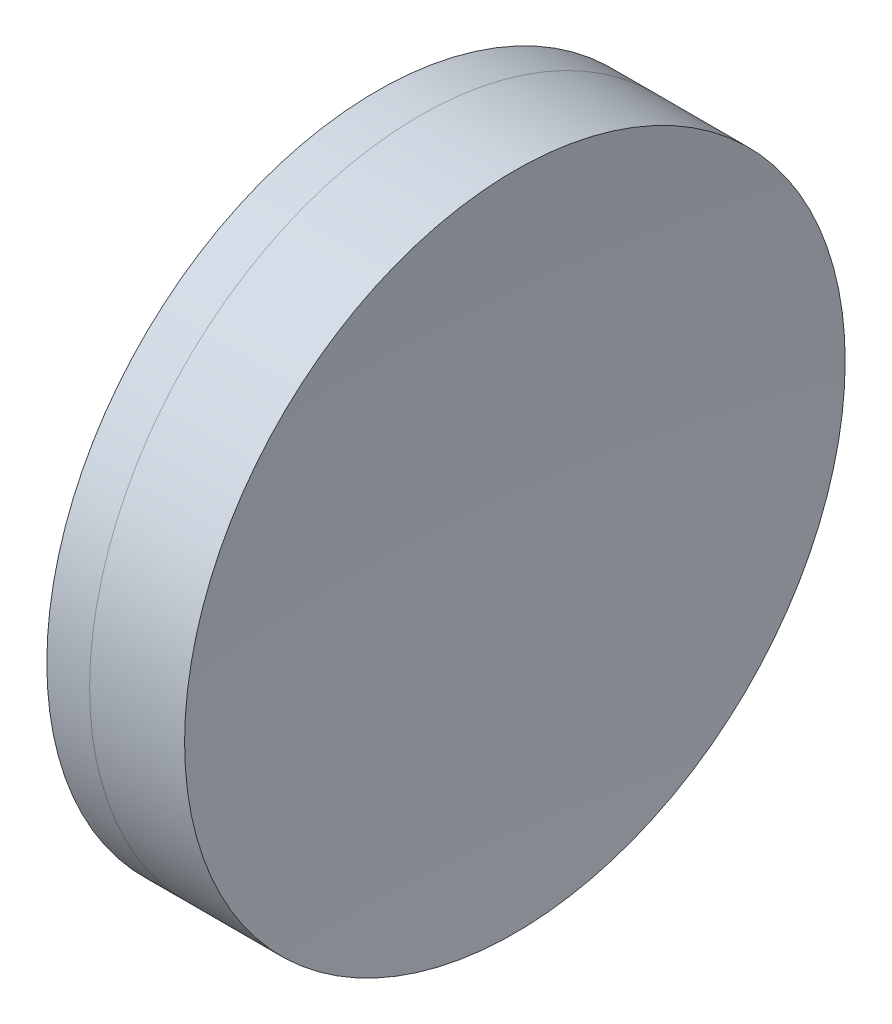
from build123d import *


with BuildPart() as part:
    # 草图1 one side → 旋转1 (revolve)
    with BuildSketch(Plane(origin=(0, 0, 0), x_dir=(1, 0, 0), z_dir=(0, 1, 0)), mode=Mode.PRIVATE) as revolve_1_sk:
        with BuildLine():
            ThreePointArc((337.646555739, 12.7), (336.667872536, 6.383490075), (336.340499792, 0))
            Line((336.340499792, 0), (340.340499792, 0))
            ThreePointArc((340.340499792, 0), (340.077795453, 6.371626018), (339.291465732, 12.7))
            Line((339.291465732, 12.7), (337.646555739, 12.7))
        make_face()
    revolve(revolve_1_sk.sketch.rotate(Axis((124.523309526, 0, 0), (1, 0, 0)), 180), axis=Axis((124.523309526, 0, 0), (1, 0, 0)))  # turned: the seam where the file's is


with BuildPart() as body_2:
    # 草图2 one side → 旋转3 (revolve)
    with BuildSketch(Plane(origin=(0, 0, 0), x_dir=(1, 0, 0), z_dir=(0, 1, 0)), mode=Mode.PRIVATE) as revolve_3_sk:
        with BuildLine():
            Line((342.943685737, 12.7), (339.291465732, 12.7))
            ThreePointArc((339.291465732, 12.7), (340.077795453, 6.371626018), (340.340499792, 0))
            Line((340.340499792, 0), (342.340499792, 0))
            ThreePointArc((342.340499792, 0), (342.491381223, 6.357158038), (342.943685737, 12.7))
        make_face()
    revolve(revolve_3_sk.sketch.rotate(Axis((-0.551919993, 0, 0), (1, 0, 0)), 180), axis=Axis((-0.551919993, 0, 0), (1, 0, 0)))  # turned: the seam where the file's is


solid = Compound([part.part, body_2.part])
